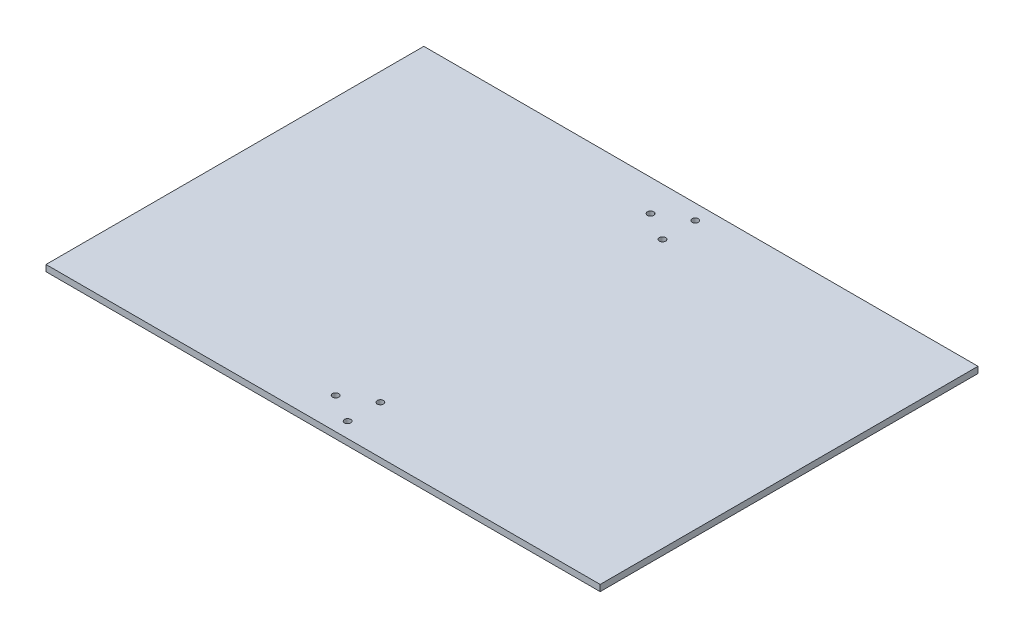
from build123d import *

# Parameters (mm, degrees)
SKETCH1_W           = 1117.6
SKETCH1_H           = 762
BOSS_EXTRUDE3_DEPTH = 12.7
SKETCH3_R           = 6.35
CUT_EXTRUDE1_DEPTH  = 12.7


with BuildPart() as part:
    # Sketch1 → Boss-Extrude3 (new body)
    with BuildSketch(Plane(origin=(0, 0, 0), x_dir=(1, 0, 0), z_dir=(0, 1, 0))):
        Rectangle(SKETCH1_W, SKETCH1_H)
    extrude(amount=-BOSS_EXTRUDE3_DEPTH)

    # Sketch3 → Cut-Extrude1 (cut)
    with BuildSketch(Plane(origin=(0, 0, 0), x_dir=(1, 0, 0), z_dir=(0, 1, 0))):
        with Locations((-38.1, 317.5)):
            Circle(SKETCH3_R)
        with Locations((19.05, 350.495567884)):
            Circle(SKETCH3_R)
        with Locations((19.05, 284.504432116)):
            Circle(SKETCH3_R)
        with Locations((19.05, -350.495567884)):
            Circle(SKETCH3_R)
        with Locations((19.05, -284.504432116)):
            Circle(SKETCH3_R)
        with Locations((-38.1, -317.5)):
            Circle(SKETCH3_R)
    extrude(amount=-CUT_EXTRUDE1_DEPTH, mode=Mode.SUBTRACT)


solid = part.part
